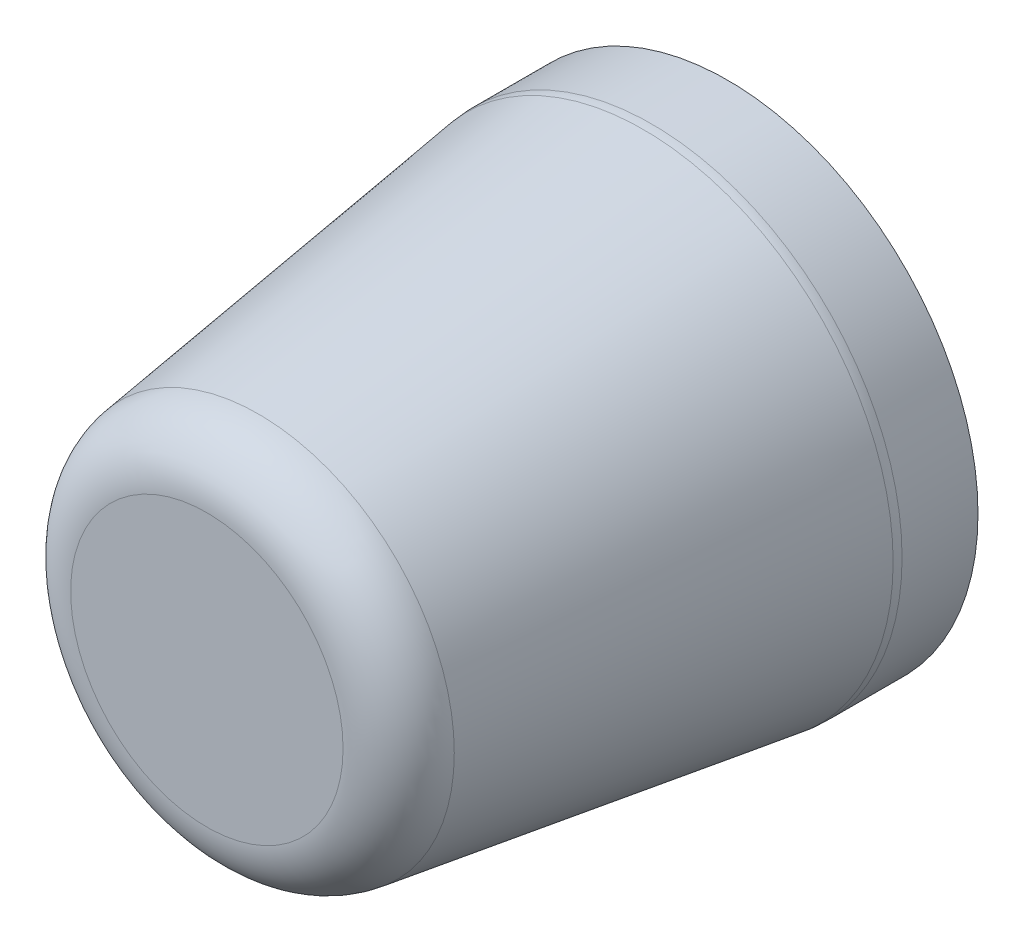
from build123d import *

# Parameters (mm, degrees)
FILLET1_R = 3


with BuildPart() as part:
    # Sketch1 → Revolve1 (revolve)
    with BuildSketch(Plane(origin=(0, 0, 0), x_dir=(0, 0, -1), z_dir=(1, 0, 0))):
        Polygon((-26, 0), (-15, 0), (-15, 2), (0, 2), (0, 12.5), (-4, 12.5), (-26, 9.408101637), align=None)
    revolve(axis=Axis((0, 0, 0), (0, 0, 1)))

    # Fillet1
    fillet1_edges = [part.edges().sort_by_distance(p)[0] for p in [
        (0, -9.408101637, 26),
        (0, -12.5, 4),
    ]]
    fillet(fillet1_edges, radius=FILLET1_R)


solid = part.part
